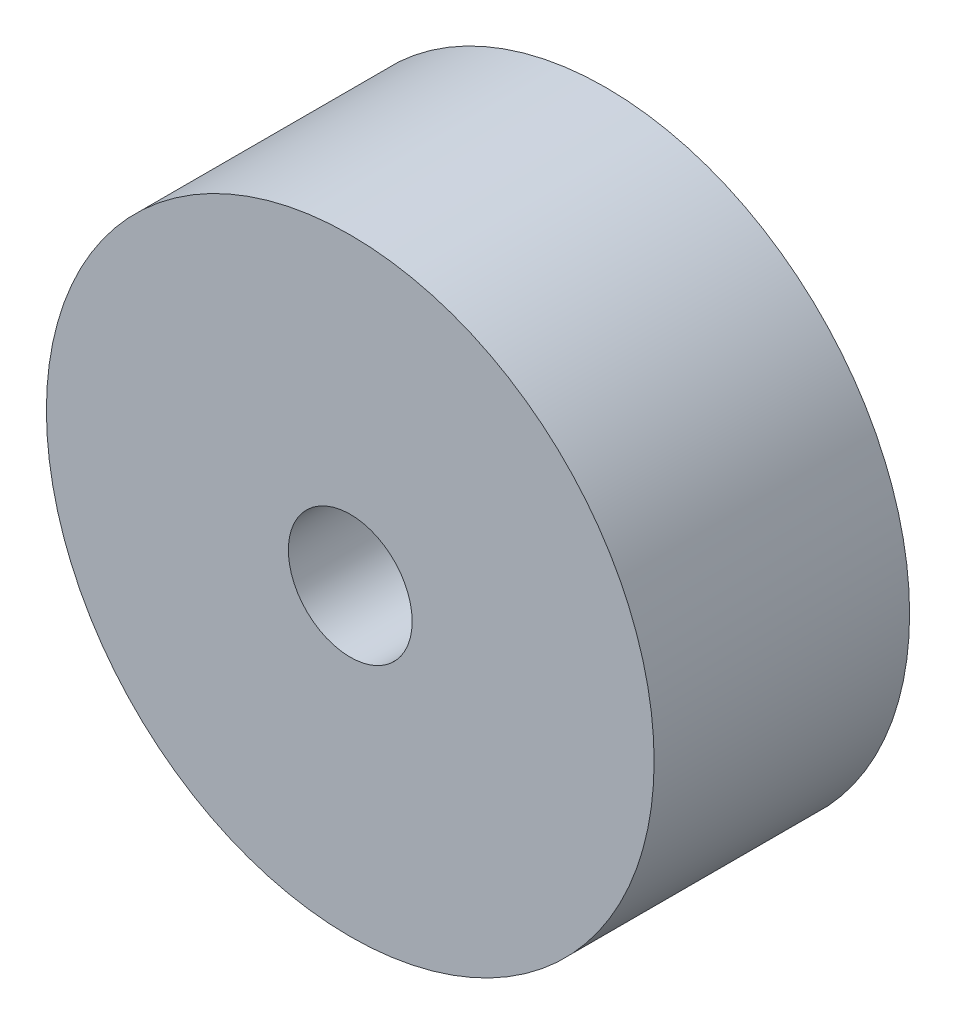
from build123d import *

# Parameters (mm, degrees)
SKETCH1_R           = 12.025
BOSS_EXTRUDE1_DEPTH = 10.11
SKETCH2_R           = 2.45
CUT_EXTRUDE1_DEPTH  = 10.11


with BuildPart() as part:
    # Sketch1 → Boss-Extrude1 (new body)
    with BuildSketch(Plane.XY):
        Circle(SKETCH1_R)
    extrude(amount=BOSS_EXTRUDE1_DEPTH)

    # Sketch2 → Cut-Extrude1 (cut)
    with BuildSketch(Plane.XY.offset(10.11)):
        Circle(SKETCH2_R)
    extrude(amount=-CUT_EXTRUDE1_DEPTH, mode=Mode.SUBTRACT)


solid = part.part
